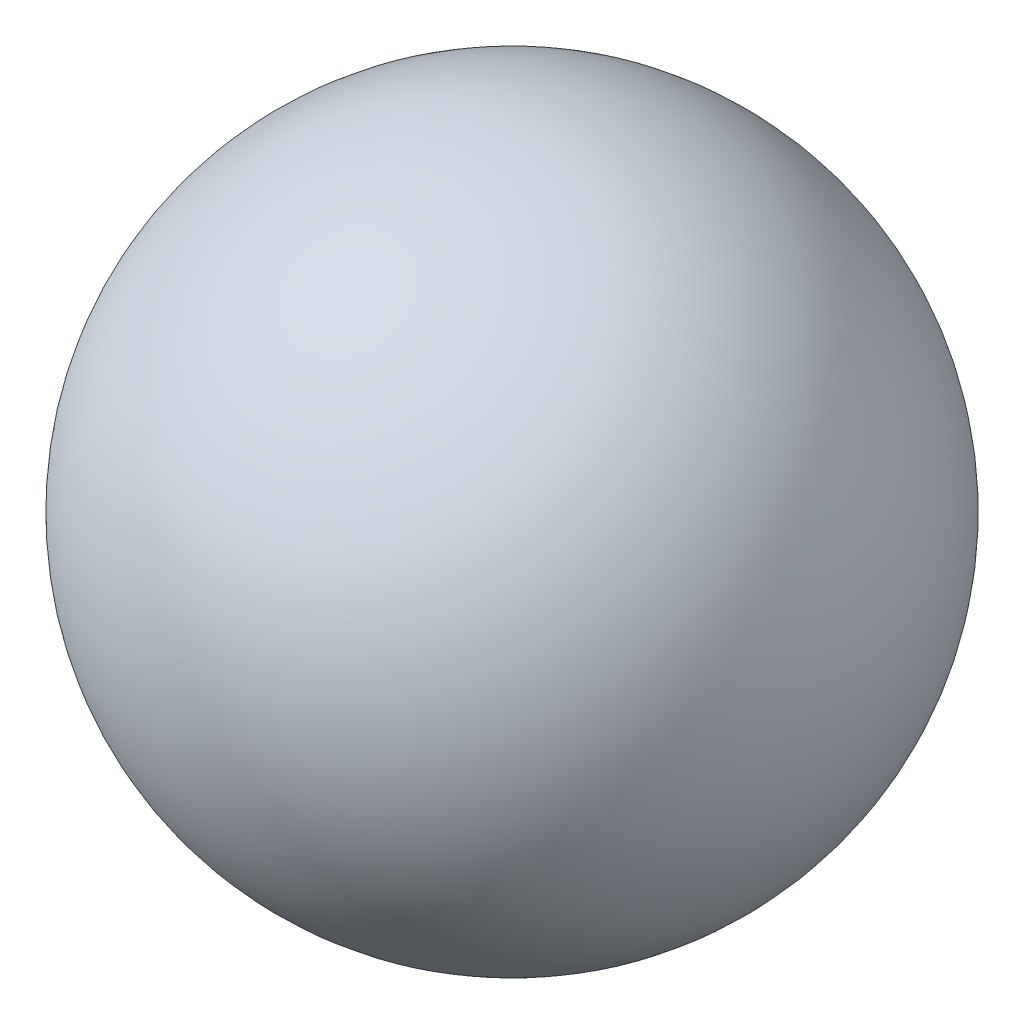
from build123d import *


with BuildPart() as part:
    # Sketch1 → Revolve1 (revolve)
    with BuildSketch(Plane.XY):
        with BuildLine():
            Line((0, 127), (0, -127))
            ThreePointArc((0, -127), (127, 0), (0, 127))
        make_face()
    revolve(axis=Axis((0, 127, 0), (0, -1, 0)))


solid = part.part
